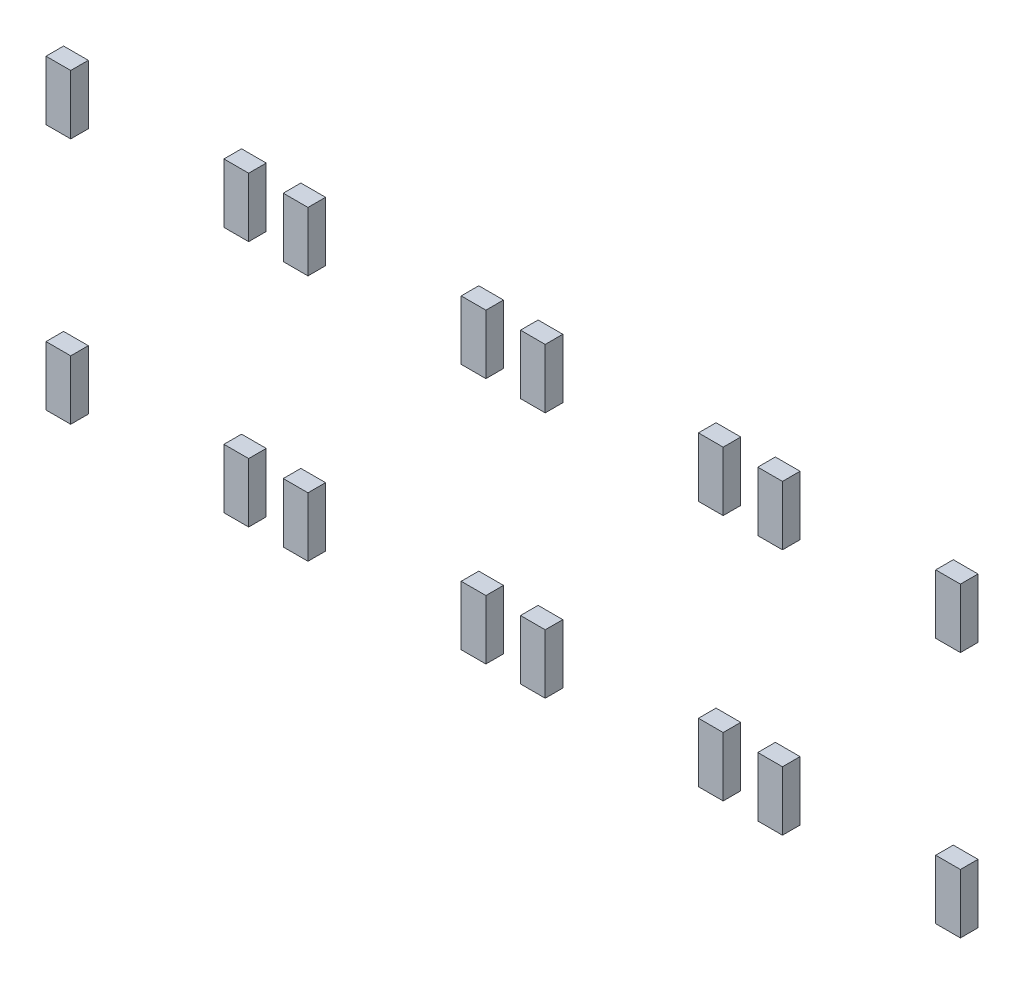
from build123d import *

# Parameters (mm, degrees)
SKETCH1_W              = 2.5
SKETCH1_H              = 6
BOSS_EXTRUDE1_DEPTH    = 1.78
BOSS_EXTRUDE1_2_DEPTH  = 1.78
BOSS_EXTRUDE1_3_DEPTH  = 1.78
BOSS_EXTRUDE1_4_DEPTH  = 1.78
BOSS_EXTRUDE1_5_DEPTH  = 1.78
BOSS_EXTRUDE1_6_DEPTH  = 1.78
BOSS_EXTRUDE1_7_DEPTH  = 1.78
BOSS_EXTRUDE1_8_DEPTH  = 1.78
BOSS_EXTRUDE1_9_DEPTH  = 1.78
BOSS_EXTRUDE1_10_DEPTH = 1.78
BOSS_EXTRUDE1_11_DEPTH = 1.78
BOSS_EXTRUDE1_12_DEPTH = 1.78
BOSS_EXTRUDE1_13_DEPTH = 1.78
BOSS_EXTRUDE1_14_DEPTH = 1.78
BOSS_EXTRUDE1_15_DEPTH = 1.78
BOSS_EXTRUDE1_16_DEPTH = 1.78


with BuildPart() as part:
    # Sketch1 → Boss-Extrude1 (new body)
    with BuildSketch(Plane.XY):
        with Locations((23, -37.5)):
            Rectangle(SKETCH1_W, SKETCH1_H)
    extrude(amount=BOSS_EXTRUDE1_DEPTH)


with BuildPart() as body_2:
    # Sketch1 → Boss-Extrude1 2 (new body)
    with BuildSketch(Plane.XY):
        with Locations((5, -37.5)):
            Rectangle(SKETCH1_W, SKETCH1_H)
    extrude(amount=BOSS_EXTRUDE1_2_DEPTH)


with BuildPart() as body_3:
    # Sketch1 → Boss-Extrude1 3 (new body)
    with BuildSketch(Plane.XY):
        with Locations((5, -62.5)):
            Rectangle(SKETCH1_W, SKETCH1_H)
    extrude(amount=BOSS_EXTRUDE1_3_DEPTH)


with BuildPart() as body_4:
    # Sketch1 → Boss-Extrude1 4 (new body)
    with BuildSketch(Plane.XY):
        with Locations((23, -62.5)):
            Rectangle(SKETCH1_W, SKETCH1_H)
    extrude(amount=BOSS_EXTRUDE1_4_DEPTH)


with BuildPart() as body_5:
    # Sketch1 → Boss-Extrude1 5 (new body)
    with BuildSketch(Plane.XY):
        with Locations((47, -37.5)):
            Rectangle(SKETCH1_W, SKETCH1_H)
    extrude(amount=BOSS_EXTRUDE1_5_DEPTH)


with BuildPart() as body_6:
    # Sketch1 → Boss-Extrude1 6 (new body)
    with BuildSketch(Plane.XY):
        with Locations((29, -37.5)):
            Rectangle(SKETCH1_W, SKETCH1_H)
    extrude(amount=BOSS_EXTRUDE1_6_DEPTH)


with BuildPart() as body_7:
    # Sketch1 → Boss-Extrude1 7 (new body)
    with BuildSketch(Plane.XY):
        with Locations((29, -62.5)):
            Rectangle(SKETCH1_W, SKETCH1_H)
    extrude(amount=BOSS_EXTRUDE1_7_DEPTH)


with BuildPart() as body_8:
    # Sketch1 → Boss-Extrude1 8 (new body)
    with BuildSketch(Plane.XY):
        with Locations((47, -62.5)):
            Rectangle(SKETCH1_W, SKETCH1_H)
    extrude(amount=BOSS_EXTRUDE1_8_DEPTH)


with BuildPart() as body_9:
    # Sketch1 → Boss-Extrude1 9 (new body)
    with BuildSketch(Plane.XY):
        with Locations((71, -37.5)):
            Rectangle(SKETCH1_W, SKETCH1_H)
    extrude(amount=BOSS_EXTRUDE1_9_DEPTH)


with BuildPart() as body_10:
    # Sketch1 → Boss-Extrude1 10 (new body)
    with BuildSketch(Plane.XY):
        with Locations((53, -37.5)):
            Rectangle(SKETCH1_W, SKETCH1_H)
    extrude(amount=BOSS_EXTRUDE1_10_DEPTH)


with BuildPart() as body_11:
    # Sketch1 → Boss-Extrude1 11 (new body)
    with BuildSketch(Plane.XY):
        with Locations((53, -62.5)):
            Rectangle(SKETCH1_W, SKETCH1_H)
    extrude(amount=BOSS_EXTRUDE1_11_DEPTH)


with BuildPart() as body_12:
    # Sketch1 → Boss-Extrude1 12 (new body)
    with BuildSketch(Plane.XY):
        with Locations((71, -62.5)):
            Rectangle(SKETCH1_W, SKETCH1_H)
    extrude(amount=BOSS_EXTRUDE1_12_DEPTH)


with BuildPart() as body_13:
    # Sketch1 → Boss-Extrude1 13 (new body)
    with BuildSketch(Plane.XY):
        with Locations((95, -37.5)):
            Rectangle(SKETCH1_W, SKETCH1_H)
    extrude(amount=BOSS_EXTRUDE1_13_DEPTH)


with BuildPart() as body_14:
    # Sketch1 → Boss-Extrude1 14 (new body)
    with BuildSketch(Plane.XY):
        with Locations((77, -37.5)):
            Rectangle(SKETCH1_W, SKETCH1_H)
    extrude(amount=BOSS_EXTRUDE1_14_DEPTH)


with BuildPart() as body_15:
    # Sketch1 → Boss-Extrude1 15 (new body)
    with BuildSketch(Plane.XY):
        with Locations((77, -62.5)):
            Rectangle(SKETCH1_W, SKETCH1_H)
    extrude(amount=BOSS_EXTRUDE1_15_DEPTH)


with BuildPart() as body_16:
    # Sketch1 → Boss-Extrude1 16 (new body)
    with BuildSketch(Plane.XY):
        with Locations((95, -62.5)):
            Rectangle(SKETCH1_W, SKETCH1_H)
    extrude(amount=BOSS_EXTRUDE1_16_DEPTH)


solid = Compound([part.part, body_2.part, body_3.part, body_4.part, body_5.part, body_6.part, body_7.part, body_8.part, body_9.part, body_10.part, body_11.part, body_12.part, body_13.part, body_14.part, body_15.part, body_16.part])
